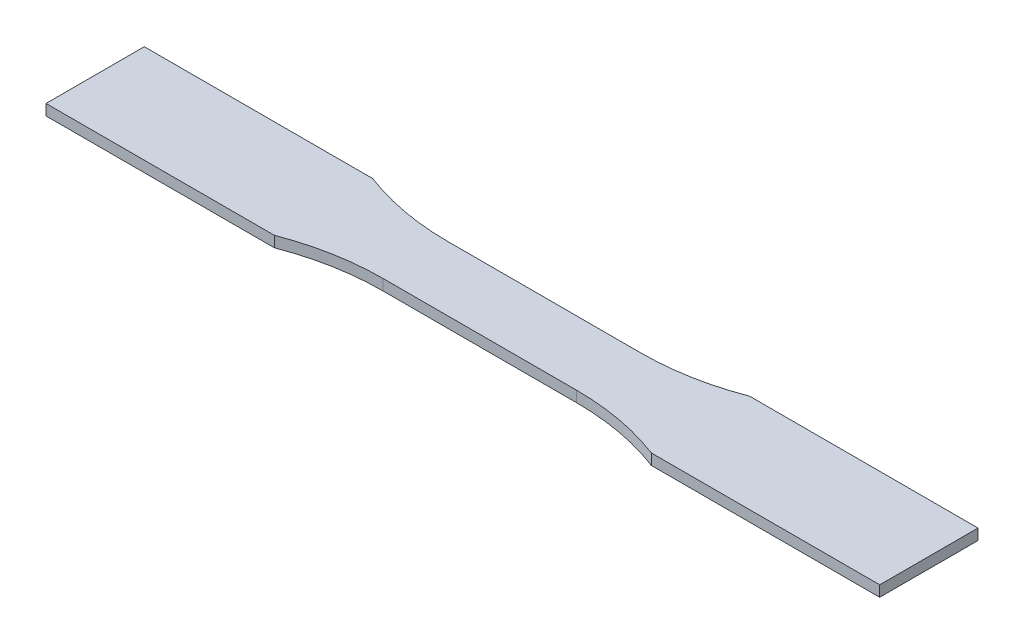
from build123d import *

# Parameters (mm, degrees)
CROQUIS1_W              = 57
CROQUIS1_H              = 19
SALIENTE_EXTRUIR1_DEPTH = 1.6


with BuildPart() as part:
    # Croquis1 → Saliente-Extruir1 (new body, symmetric)
    with BuildSketch(Plane(origin=(0, 0, 0), x_dir=(1, 0, 0), z_dir=(0, 1, 0))):
        with BuildLine():
            Line((-123, -14.5), (-55.610883423, -14.5))
            ThreePointArc((-55.610883423, -14.5), (-42.284048752, -10.760452236), (-28.5, -9.5))
            Line((-28.5, -9.5), (-28.5, 9.5))
            ThreePointArc((-28.5, 9.5), (-42.284048752, 10.760452236), (-55.610883423, 14.5))
            Line((-55.610883423, 14.5), (-123, 14.5))
            Line((-123, 14.5), (-123, -14.5))
        make_face()
        with BuildLine():
            Line((55.610883423, -14.5), (123, -14.5))
            Line((123, -14.5), (123, 14.5))
            Line((123, 14.5), (55.610883423, 14.5))
            ThreePointArc((55.610883423, 14.5), (42.284048752, 10.760452236), (28.5, 9.5))
            Line((28.5, 9.5), (28.5, -9.5))
            ThreePointArc((28.5, -9.5), (42.284048752, -10.760452236), (55.610883423, -14.5))
        make_face()
        Rectangle(CROQUIS1_W, CROQUIS1_H)
    extrude(amount=SALIENTE_EXTRUIR1_DEPTH, both=True)


solid = part.part
